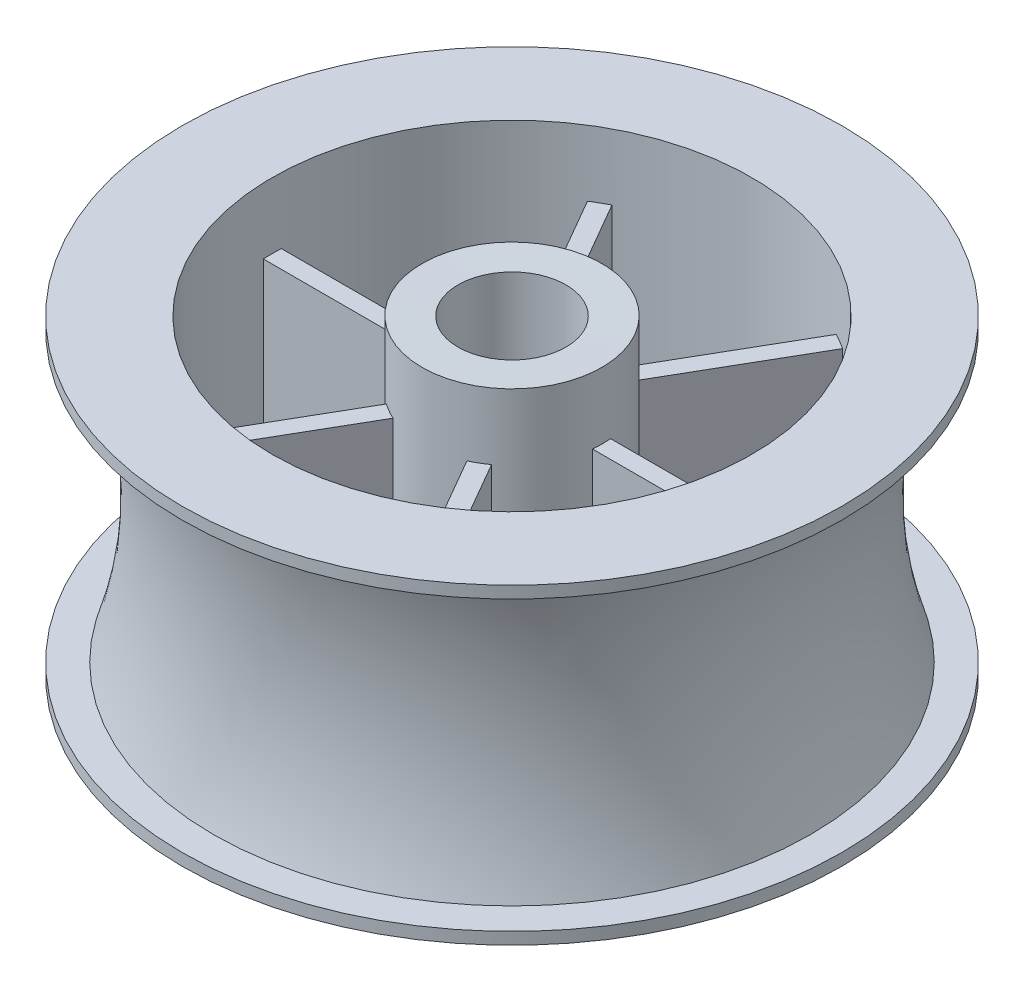
from build123d import *

# Parameters (mm, degrees)
BOSS_EXTRUDE1_START = 5.5
SKETCH4_W           = 13.614691885
SKETCH4_H           = 1.5
BOSS_EXTRUDE1_DEPTH = 15


with BuildPart() as part:
    # Sketch1 → Revolve1 (revolve)
    with BuildSketch(Plane.XY):
        with BuildLine():
            Line((-20, 26), (-27.5, 26))
            Line((-27.5, 26), (-27.5, 25))
            Line((-27.5, 25), (-24.9, 25))
            ThreePointArc((-24.9, 25), (-23.057568057, 13), (-24.9, 1))
            Line((-24.9, 1), (-27.5, 1))
            Line((-27.5, 1), (-27.5, 0))
            Line((-27.5, 0), (-20, 0))
            Line((-20, 0), (-20, 5.5))
            Line((-20, 5.5), (-20, 20.5))
            Line((-20, 20.5), (-20, 26))
        make_face()
        Polygon((-4.5, 26), (-4.5, 0), (-7.5, 0), (-7.5, 5.5), (-7.5, 20.5), (-7.5, 26.037065381), align=None)
    revolve(axis=Axis((0, 42.404735677, 0), (0, -1, 0)))

    # Sketch4 → Boss-Extrude1 (add)
    with BuildSketch(Plane(origin=(0, 0, 0), x_dir=(1, 0, 0), z_dir=(0, 1, 0)).offset(BOSS_EXTRUDE1_START)):
        with Locations((13.641384633, 0)):
            Rectangle(SKETCH4_W, SKETCH4_H)
        Polygon((4.066538398, -5.543451116), (10.873884341, -17.334120153), (9.574846235, -18.084120153), (2.767500292, -6.293451116), align=None)
        Polygon((-2.767500292, -6.293451116), (-9.574846235, -18.084120153), (-10.873884341, -17.334120153), (-4.066538398, -5.543451116), align=None)
        with Locations((-13.641384633, 0)):
            Rectangle(SKETCH4_W, SKETCH4_H)
        Polygon((-4.066538398, 5.543451116), (-10.873884341, 17.334120153), (-9.574846235, 18.084120153), (-2.767500292, 6.293451116), align=None)
        Polygon((2.767500292, 6.293451116), (9.574846235, 18.084120153), (10.873884341, 17.334120153), (4.066538398, 5.543451116), align=None)
    extrude(amount=BOSS_EXTRUDE1_DEPTH)


solid = part.part
